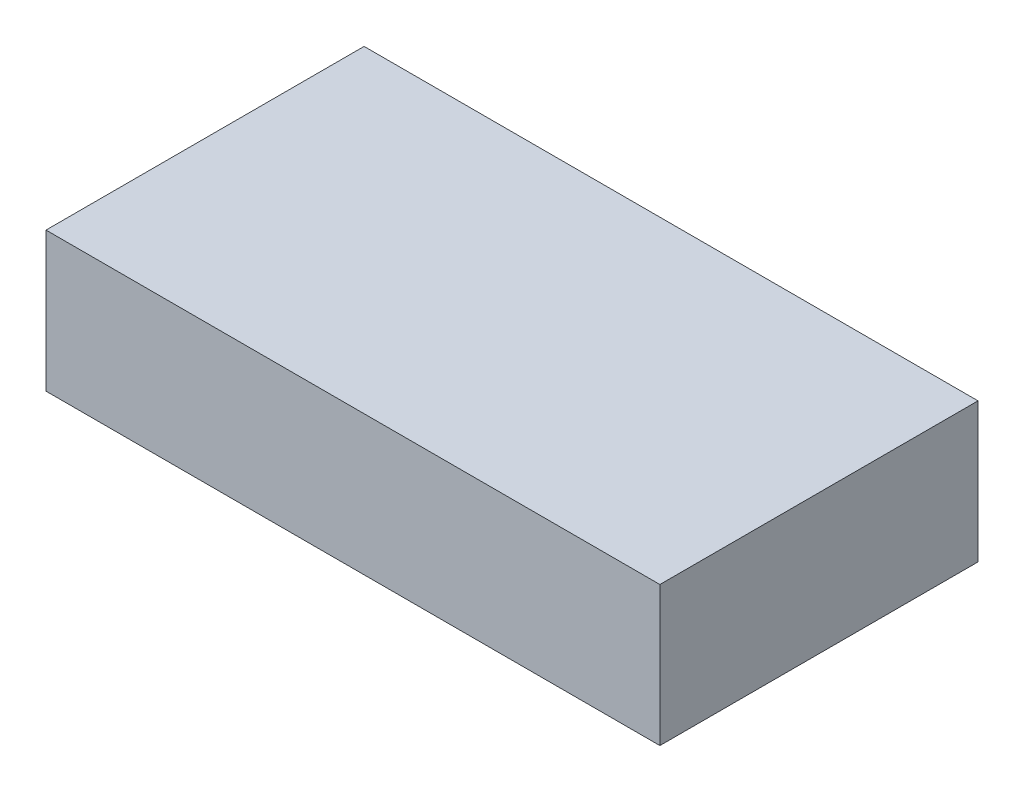
from build123d import *

# Parameters (mm, degrees)
SKETCH1_W           = 220
SKETCH1_H           = 114
BOSS_EXTRUDE1_DEPTH = 50


with BuildPart() as part:
    # Sketch1 → Boss-Extrude1 (new body)
    with BuildSketch(Plane(origin=(0, 0, 0), x_dir=(1, 0, 0), z_dir=(0, 1, 0))):
        Rectangle(SKETCH1_W, SKETCH1_H)
    extrude(amount=BOSS_EXTRUDE1_DEPTH)


solid = part.part
